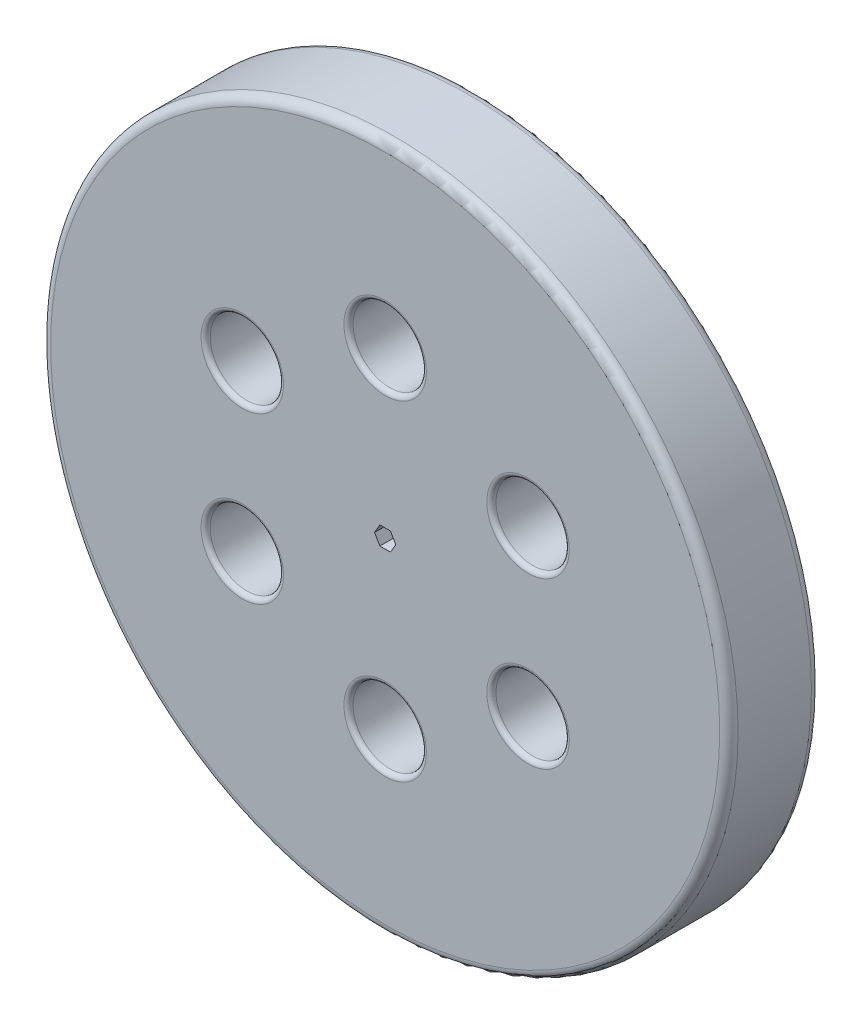
from build123d import *

# Parameters (mm, degrees)
SKETCH1_R           = 37.5
BOSS_EXTRUDE1_DEPTH = 10
SKETCH3_R           = 4
CUT_EXTRUDE3_DEPTH  = 11
CIRPATTERN1_COUNT   = 6
FILLET1_R           = 1
FILLET2_R           = 0.5
CUT_EXTRUDE4_DEPTH  = 10


with BuildPart() as part:
    # Sketch1 → Boss-Extrude1 (new body)
    with BuildSketch(Plane.XY):
        Circle(SKETCH1_R)
    extrude(amount=BOSS_EXTRUDE1_DEPTH)

    # Sketch3 → Cut-Extrude3 (cut, through all)
    with BuildSketch(Plane.XY.offset(10)):
        with Locations((0, 18)):
            Circle(SKETCH3_R)
    cut_extrude3 = extrude(amount=-CUT_EXTRUDE3_DEPTH, mode=Mode.SUBTRACT)

    # CirPattern1: Cut-Extrude3 ×6 about axis
    cirpattern1_axis = Axis((0, 0, 0), (0, 0, 1))
    for i in range(1, CIRPATTERN1_COUNT):
        add(cut_extrude3.rotate(cirpattern1_axis, i * 360 / CIRPATTERN1_COUNT), mode=Mode.SUBTRACT)

    # Fillet1
    fillet1_edges = [part.edges().sort_by_distance(p)[0] for p in [
        (-37.5, 0, 0),
        (-37.5, 0, 10),
    ]]
    fillet(fillet1_edges, radius=FILLET1_R)

    # Fillet2
    fillet2_edges = [part.edges().sort_by_distance(p)[0] for p in [
        (13.588457268, 12.464101615, 0),
        (13.588457268, 12.464101615, 10),
        (17.588457268, -5.535898385, 0),
        (17.588457268, -5.535898385, 10),
        (4, -18, 0),
        (4, -18, 10),
        (-13.588457268, -12.464101615, 0),
        (-13.588457268, -12.464101615, 10),
        (-17.588457268, 5.535898385, 0),
        (-17.588457268, 5.535898385, 10),
        (-4, 18, 0),
        (-4, 18, 10),
    ]]
    fillet(fillet2_edges, radius=FILLET2_R)

    # Sketch2 → Cut-Extrude4 (cut)
    with BuildSketch(Plane.XY.offset(10)):
        Polygon((1.154700538, 0), (0.577350269, 1), (-0.577350269, 1), (-1.154700538, 0), (-0.577350269, -1), (0.577350269, -1), align=None)
    extrude(amount=-CUT_EXTRUDE4_DEPTH, mode=Mode.SUBTRACT)


solid = part.part
